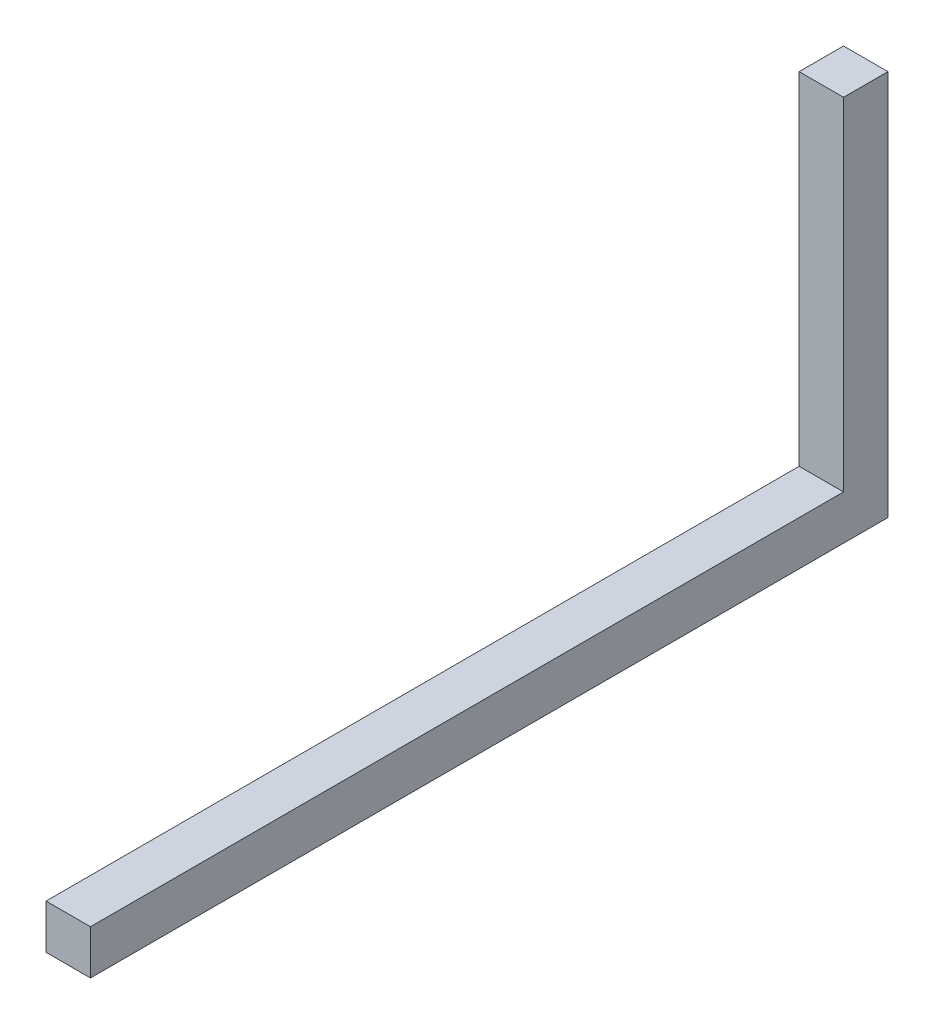
from build123d import *

# Parameters (mm, degrees)
SKETCH1_W           = 11.5
SKETCH1_H           = 11.5
BOSS_EXTRUDE1_DEPTH = 195
BOSS_EXTRUDE2_START = -5.75
SKETCH2_W           = 11.5
SKETCH2_H           = 11.5
BOSS_EXTRUDE2_DEPTH = 100


with BuildPart() as part:
    # Sketch1 → Boss-Extrude1 (new body)
    with BuildSketch(Plane.XY):
        Rectangle(SKETCH1_W, SKETCH1_H)
    extrude(amount=BOSS_EXTRUDE1_DEPTH)

    # Sketch2 → Boss-Extrude2 (add)
    with BuildSketch(Plane(origin=(0, 0, 0), x_dir=(1, 0, 0), z_dir=(0, 1, 0)).offset(BOSS_EXTRUDE2_START)):
        with Locations((0, 5.75)):
            Rectangle(SKETCH2_W, SKETCH2_H)
    extrude(amount=BOSS_EXTRUDE2_DEPTH)


solid = part.part
